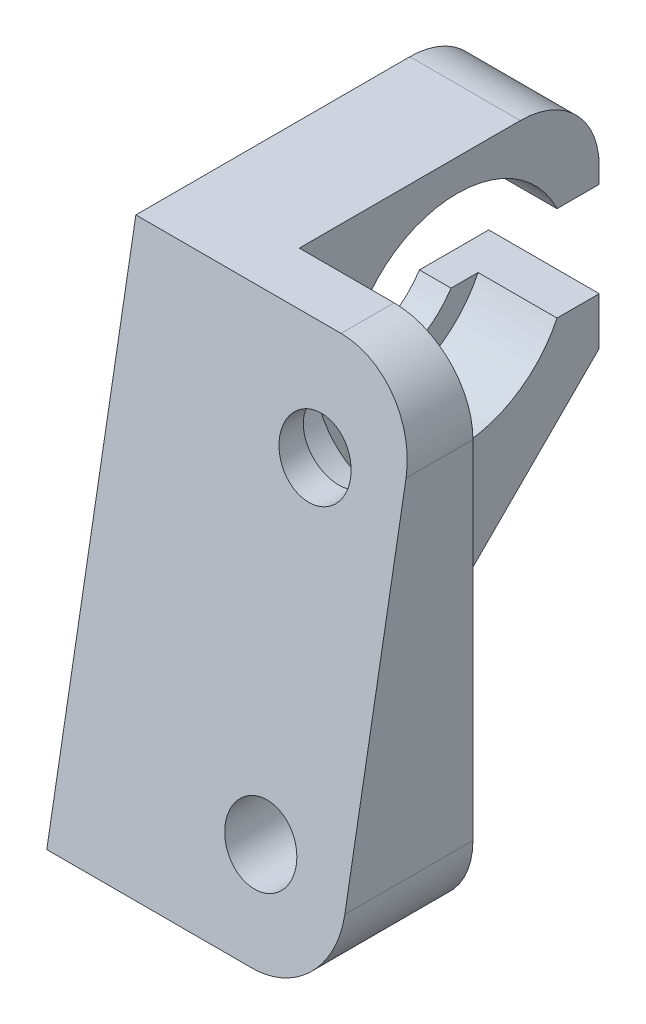
from build123d import *

# Parameters (mm, degrees)
BOSS_EXTRU_1_DEPTH                                 = 18
ESQUISSE2_W                                        = 11
ESQUISSE2_H                                        = 19
ENL_V_MAT_EXTRU_1_DEPTH                            = 33
CHAMBRAGE_POUR_VIS_T_TE_HEXAGONALE_M41_D           = 4.5
CHAMBRAGE_POUR_VIS_T_TE_HEXAGONALE_M41_CBORE_D     = 8
CHAMBRAGE_POUR_VIS_T_TE_HEXAGONALE_M41_CBORE_DEPTH = 4.4
CHAMBRAGE_POUR_VIS_T_TE_HEXAGONALE_M44_D           = 4.5
CHAMBRAGE_POUR_VIS_T_TE_HEXAGONALE_M44_CBORE_D     = 9
CHAMBRAGE_POUR_VIS_T_TE_HEXAGONALE_M44_CBORE_DEPTH = 3
ESQUISSE9_R                                        = 5.5
ENL_V_MAT_EXTRU_2_DEPTH                            = 8
ESQUISSE10_R                                       = 7
ENL_V_MAT_EXTRU_3_DEPTH                            = 5
ESQUISSE11_W                                       = 9
ESQUISSE11_H                                       = 6
ENL_V_MAT_EXTRU_4_DEPTH                            = 8
CHANFREIN1_SIZE                                    = 17
CONG_1_R                                           = 5
CONG_2_R                                           = 5


with BuildPart() as part:
    # Esquisse1 → Boss.-Extru.1 (new body)
    with BuildSketch(Plane(origin=(0, 0, 0), x_dir=(0, 0, -1), z_dir=(1, 0, 0))):
        Polygon((0, 0), (5.642463383, 32), (28, 32), (28, 0), align=None)
    extrude(amount=BOSS_EXTRU_1_DEPTH)

    # Esquisse2 → Enlèv. mat.-Extru.1 (cut, through all)
    with BuildSketch(Plane(origin=(0, 32, 0), x_dir=(1, 0, 0), z_dir=(0, 1, 0))):
        with Locations((12.5, 18.5)):
            Rectangle(ESQUISSE2_W, ESQUISSE2_H)
    extrude(amount=-ENL_V_MAT_EXTRU_1_DEPTH, mode=Mode.SUBTRACT)

    # Chambrage pour vis à tête hexagonale M41 (through all)
    with Locations(Plane(origin=(0, 0, -9), x_dir=(-1, 0, 0), z_dir=(0, 0, -1))):
        with Locations((-12.5, 6)):
            CounterBoreHole(CHAMBRAGE_POUR_VIS_T_TE_HEXAGONALE_M41_D / 2, CHAMBRAGE_POUR_VIS_T_TE_HEXAGONALE_M41_CBORE_D / 2, CHAMBRAGE_POUR_VIS_T_TE_HEXAGONALE_M41_CBORE_DEPTH)

    # Chambrage pour vis à tête hexagonale M44 (through all)
    with Locations(Plane(origin=(0, 0, -9), x_dir=(-1, 0, 0), z_dir=(0, 0, -1))):
        with Locations((-12.5, 25.5)):
            CounterBoreHole(CHAMBRAGE_POUR_VIS_T_TE_HEXAGONALE_M44_D / 2, CHAMBRAGE_POUR_VIS_T_TE_HEXAGONALE_M44_CBORE_D / 2, CHAMBRAGE_POUR_VIS_T_TE_HEXAGONALE_M44_CBORE_DEPTH)

    # Esquisse9 → Enlèv. mat.-Extru.2 (cut, through all)
    with BuildSketch(Plane(origin=(7, 0, 0), x_dir=(0, 0, -1), z_dir=(1, 0, 0))):
        with Locations((19, 23)):
            Circle(ESQUISSE9_R)
    extrude(amount=-ENL_V_MAT_EXTRU_2_DEPTH, mode=Mode.SUBTRACT)

    # Esquisse10 → Enlèv. mat.-Extru.3 (cut)
    with BuildSketch(Plane(origin=(7, 0, 0), x_dir=(0, 0, -1), z_dir=(1, 0, 0))):
        with Locations((19, 23)):
            Circle(ESQUISSE10_R)
    extrude(amount=-ENL_V_MAT_EXTRU_3_DEPTH, mode=Mode.SUBTRACT)

    # Esquisse11 → Enlèv. mat.-Extru.4 (cut, through all)
    with BuildSketch(Plane(origin=(7, 0, 0), x_dir=(0, 0, -1), z_dir=(1, 0, 0))):
        with Locations((23.5, 23)):
            Rectangle(ESQUISSE11_W, ESQUISSE11_H)
    extrude(amount=-ENL_V_MAT_EXTRU_4_DEPTH, mode=Mode.SUBTRACT)

    # Chanfrein1
    chanfrein1_edges = [part.edges().sort_by_distance(p)[0] for p in [
        (3.5, 0, -28),
    ]]
    chamfer(chanfrein1_edges, length=CHANFREIN1_SIZE)

    # Congé1
    cong_1_edges = [part.edges().sort_by_distance(p)[0] for p in [
        (3.5, 32, -28),
    ]]
    fillet(cong_1_edges, radius=CONG_1_R)

    # Congé2
    cong_2_edges = [part.edges().sort_by_distance(p)[0] for p in [
        (18, 32, -7.321231691),
        (18, 0, -4.5),
    ]]
    fillet(cong_2_edges, radius=CONG_2_R)


solid = part.part
